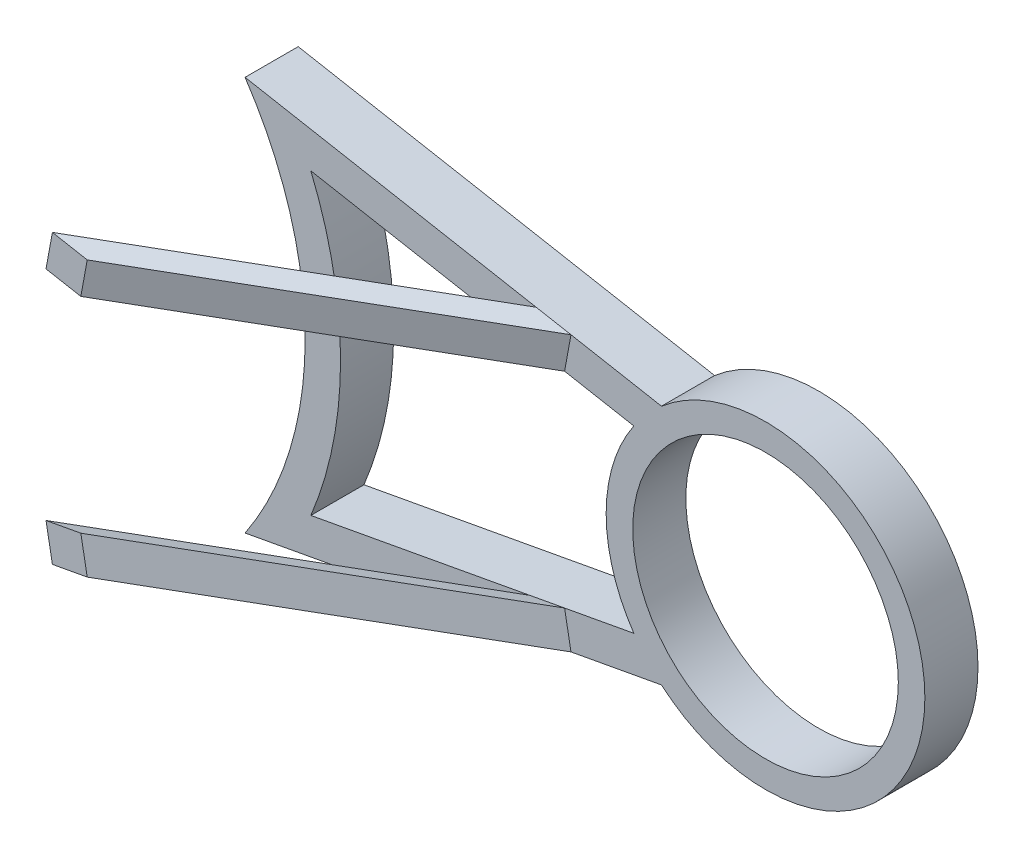
from build123d import *

# Parameters (mm, degrees)
SKETCH2_R      = 375
EXTRUDE1_DEPTH = 150
EXTRUDE2_DEPTH = 1000


with BuildPart() as part:
    # Sketch2 → Extrude1 (new body)
    with BuildSketch(Plane.XY.offset(10859.457415778)):
        with BuildLine():
            Line((4595.965460825, 3982.309677998), (3420.142893862, 4198.672715486))
            ThreePointArc((3420.142893862, 4198.672715486), (3589.772208911, 3641.46133228), (3420.142893862, 3084.249949073))
            Line((3420.142893862, 3084.249949073), (4595.965460825, 3300.612986561))
            ThreePointArc((4595.965460825, 3300.612986561), (5339.772208911, 3641.46133228), (4595.965460825, 3982.309677998))
        make_face()
        with Locations((4889.772208911, 3641.46133228)):
            Circle(SKETCH2_R, mode=Mode.SUBTRACT)
        with BuildLine():
            Line((4517.981926059, 3894.980533873), (3605.871957835, 4062.817832453))
            ThreePointArc((3605.871957835, 4062.817832453), (3689.772208911, 3641.46133228), (3605.871957835, 3220.104832106))
            Line((3605.871957835, 3220.104832106), (4517.981926059, 3387.942130686))
            ThreePointArc((4517.981926059, 3387.942130686), (4439.772208911, 3641.46133228), (4517.981926059, 3894.980533873))
        make_face(mode=Mode.SUBTRACT)
    extrude(amount=EXTRUDE1_DEPTH)

    # Sketch3 → Extrude2 (add, along a direction that is not the sketch's normal)
    with BuildSketch(Plane.XY.offset(11009.457415778)):
        Polygon((4340.484797421, 4029.320658997), (4242.135965642, 4047.417821421), (4224.038803218, 3949.068989643), (4322.387634996, 3930.971827218), align=None)
        Polygon((4322.387634996, 3351.950837341), (4224.038803218, 3333.853674916), (4242.135965642, 3235.504843138), (4340.484797421, 3253.602005562), align=None)
    extrude(amount=EXTRUDE2_DEPTH, dir=(-0.866025404, 0, 0.5))


solid = part.part
